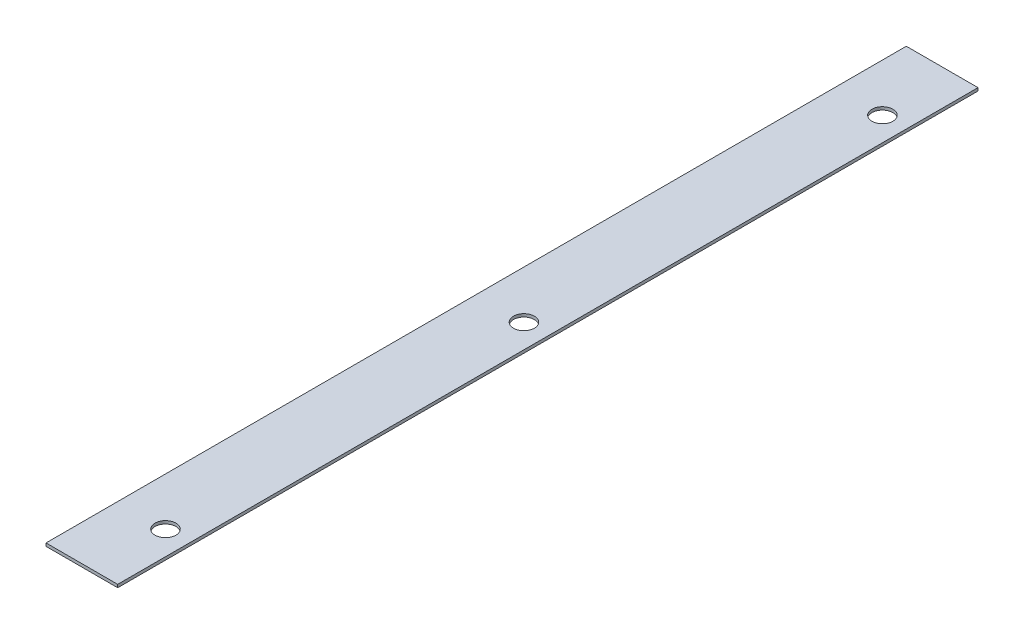
from build123d import *

# Parameters (mm, degrees)
SKETCH1_W           = 76.2
SKETCH1_H           = 914.4
BOSS_EXTRUDE1_DEPTH = 3.175
CUT_EXTRUDE1_REACH  = 5.175
SKETCH2_R           = 11.1125


with BuildPart() as part:
    # Sketch1 → Boss-Extrude1 (new body)
    with BuildSketch(Plane(origin=(0, 0, 0), x_dir=(1, 0, 0), z_dir=(0, 1, 0))):
        with Locations((38.1, 457.2)):
            Rectangle(SKETCH1_W, SKETCH1_H)
    extrude(amount=BOSS_EXTRUDE1_DEPTH)

    # Sketch2 → Cut-Extrude1 (cut, up to next)
    with BuildSketch(Plane(origin=(0, 3.175, 0), x_dir=(1, 0, 0), z_dir=(0, 1, 0)), mode=Mode.PRIVATE) as cut_extrude1_sk1:
        with Locations((50.8, 838.2)):
            Circle(SKETCH2_R)
    cut_extrude1_tool1 = extrude(cut_extrude1_sk1.sketch, amount=-CUT_EXTRUDE1_REACH, mode=Mode.PRIVATE) & part.part
    add(cut_extrude1_tool1.solids().sort_by_distance((50.8, 3.175, -838.2))[0], mode=Mode.SUBTRACT)
    # Sketch2 → Cut-Extrude1 (cut, up to next)
    with BuildSketch(Plane(origin=(0, 3.175, 0), x_dir=(1, 0, 0), z_dir=(0, 1, 0)), mode=Mode.PRIVATE) as cut_extrude1_sk2:
        with Locations((50.8, 457.2)):
            Circle(SKETCH2_R)
    cut_extrude1_tool2 = extrude(cut_extrude1_sk2.sketch, amount=-CUT_EXTRUDE1_REACH, mode=Mode.PRIVATE) & part.part
    add(cut_extrude1_tool2.solids().sort_by_distance((50.8, 3.175, -457.2))[0], mode=Mode.SUBTRACT)
    # Sketch2 → Cut-Extrude1 (cut, up to next)
    with BuildSketch(Plane(origin=(0, 3.175, 0), x_dir=(1, 0, 0), z_dir=(0, 1, 0)), mode=Mode.PRIVATE) as cut_extrude1_sk3:
        with Locations((50.8, 76.2)):
            Circle(SKETCH2_R)
    cut_extrude1_tool3 = extrude(cut_extrude1_sk3.sketch, amount=-CUT_EXTRUDE1_REACH, mode=Mode.PRIVATE) & part.part
    add(cut_extrude1_tool3.solids().sort_by_distance((50.8, 3.175, -76.2))[0], mode=Mode.SUBTRACT)


solid = part.part
